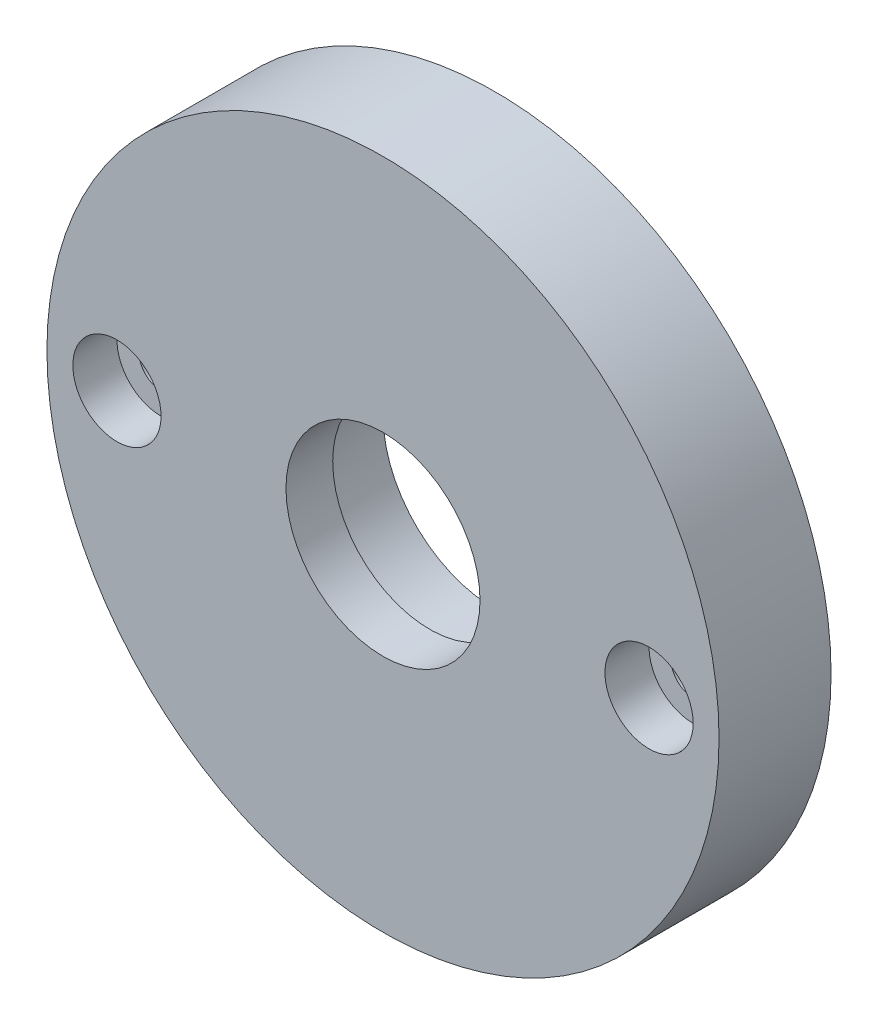
from build123d import *

# Parameters (mm, degrees)
ESQUISSE1_R             = 38.1
ESQUISSE1_R_2           = 11
BOSS_EXTRU_1_DEPTH      = 12.7
ESQUISSE2_R             = 12.7
ENL_V_MAT_EXTRU_1_DEPTH = 7.4
ESQUISSE3_R             = 2.5
ENL_V_MAT_EXTRU_2_DEPTH = 13.7
ESQUISSE4_R             = 5
ENL_V_MAT_EXTRU_3_DEPTH = 5


with BuildPart() as part:
    # Esquisse1 → Boss.-Extru.1 (new body)
    with BuildSketch(Plane.XY):
        with Locations((23.012291104, 8.435887891)):
            Circle(ESQUISSE1_R)
        with Locations((23.012291104, 8.435887891)):
            Circle(ESQUISSE1_R_2, mode=Mode.SUBTRACT)
    extrude(amount=BOSS_EXTRU_1_DEPTH)

    # Esquisse2 → Enlèv. mat.-Extru.1 (cut)
    with BuildSketch(Plane(origin=(0, 0, 0), x_dir=(-1, 0, 0), z_dir=(0, 0, -1))):
        with Locations((-23.012291104, 8.435887891)):
            Circle(ESQUISSE2_R)
    extrude(amount=-ENL_V_MAT_EXTRU_1_DEPTH, mode=Mode.SUBTRACT)

    # Esquisse3 → Enlèv. mat.-Extru.2 (cut, through all)
    with BuildSketch(Plane.XY.offset(12.7)):
        with Locations((53.174791104, 8.435887891)):
            Circle(ESQUISSE3_R)
        with Locations((-7.150208896, 8.435887891)):
            Circle(ESQUISSE3_R)
    extrude(amount=-ENL_V_MAT_EXTRU_2_DEPTH, mode=Mode.SUBTRACT)

    # Esquisse4 → Enlèv. mat.-Extru.3 (cut)
    with BuildSketch(Plane.XY.offset(12.7)):
        with Locations((-7.150208896, 8.435887891)):
            Circle(ESQUISSE4_R)
        with Locations((53.174791104, 8.435887891)):
            Circle(ESQUISSE4_R)
    extrude(amount=-ENL_V_MAT_EXTRU_3_DEPTH, mode=Mode.SUBTRACT)


solid = part.part
